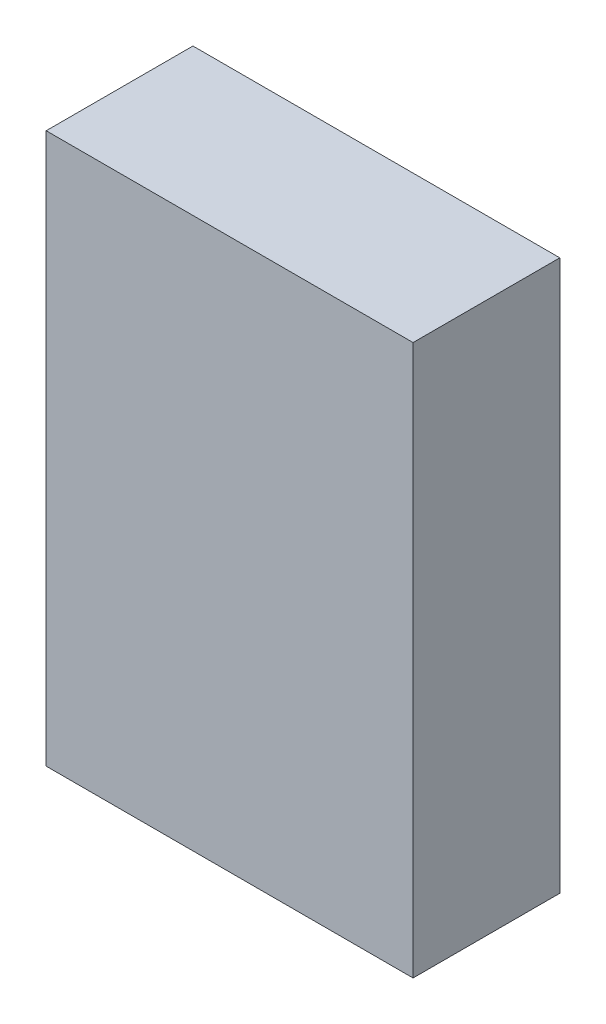
from build123d import *

# Parameters (mm, degrees)
ESQUISSE1_W             = 200
ESQUISSE1_H             = 300
BOSS_EXTRU_1_DEPTH      = 80
COQUE1_T                = -6
ESQUISSE3_W             = 194.2
ESQUISSE3_H             = 294.2
ENL_V_MAT_EXTRU_2_DEPTH = 6.1
ESQUISSE4_R             = 9
BOSS_EXTRU_2_DEPTH      = 67.9
ESQUISSE5_R             = 2.5
ENL_V_MAT_EXTRU_3_DEPTH = 30
ESQUISSE4_4_R           = 9
BOSS_EXTRU_3_DEPTH      = 15
ESQUISSE6_R             = 2.5
ENL_V_MAT_EXTRU_6_DEPTH = 10
ESQUISSE8_R             = 9
BOSS_EXTRU_5_DEPTH      = 68
ESQUISSE9_R             = 2.5
ENL_V_MAT_EXTRU_8_DEPTH = 30


with BuildPart() as part:
    # Esquisse1 → Boss.-Extru.1 (new body)
    with BuildSketch(Plane.XY):
        with Locations((43.373964051, -118.711656442)):
            Rectangle(ESQUISSE1_W, ESQUISSE1_H)
    extrude(amount=BOSS_EXTRU_1_DEPTH)

    # Coque1
    coque1_openings = [part.faces().sort_by_distance(p)[0] for p in [
        (43.373964051, -118.711656442, 0),
    ]]
    offset(amount=COQUE1_T, openings=coque1_openings, kind=Kind.INTERSECTION)

    # Esquisse3 → Enlèv. mat.-Extru.2 (cut)
    with BuildSketch(Plane(origin=(0, 0, 0), x_dir=(-1, 0, 0), z_dir=(0, 0, -1))):
        with Locations((-43.373964051, -118.711656442)):
            Rectangle(ESQUISSE3_W, ESQUISSE3_H)
    extrude(amount=-ENL_V_MAT_EXTRU_2_DEPTH, mode=Mode.SUBTRACT)

    # Esquisse4 → Boss.-Extru.2 (add)
    with BuildSketch(Plane(origin=(0, 0, 74), x_dir=(-1, 0, 0), z_dir=(0, 0, -1))):
        with Locations((-117.373964051, 5.288343558)):
            Circle(ESQUISSE4_R)
    extrude(amount=BOSS_EXTRU_2_DEPTH)

    # Esquisse5 → Enlèv. mat.-Extru.3 (cut)
    with BuildSketch(Plane(origin=(0, 0, 6.1), x_dir=(-1, 0, 0), z_dir=(0, 0, -1))):
        with Locations((-117.373964051, 5.288343558)):
            Circle(ESQUISSE5_R)
    extrude(amount=-ENL_V_MAT_EXTRU_3_DEPTH, mode=Mode.SUBTRACT)

    # Esquisse4_4 → Boss.-Extru.3 (add)
    with BuildSketch(Plane(origin=(0, 0, 74), x_dir=(-1, 0, 0), z_dir=(0, 0, -1))):
        with Locations((13.126035949, -183.711656442)):
            Circle(ESQUISSE4_4_R)
        with Locations((-99.873964051, -183.711656442)):
            Circle(ESQUISSE4_4_R)
        with Locations((-99.873964051, -53.711656442)):
            Circle(ESQUISSE4_4_R)
        with Locations((13.126035949, -53.711656442)):
            Circle(ESQUISSE4_4_R)
    extrude(amount=BOSS_EXTRU_3_DEPTH)

    # Esquisse6 → Enlèv. mat.-Extru.6 (cut)
    with BuildSketch(Plane(origin=(0, 0, 59), x_dir=(-1, 0, 0), z_dir=(0, 0, -1))):
        with Locations((-99.873964051, -53.711656442)):
            Circle(ESQUISSE6_R)
        with Locations((13.126035949, -53.711656442)):
            Circle(ESQUISSE6_R)
        with Locations((-99.873964051, -183.711656442)):
            Circle(ESQUISSE6_R)
        with Locations((13.126035949, -183.711656442)):
            Circle(ESQUISSE6_R)
    extrude(amount=-ENL_V_MAT_EXTRU_6_DEPTH, mode=Mode.SUBTRACT)

    # Esquisse8 → Boss.-Extru.5 (add)
    with BuildSketch(Plane(origin=(0, 0, 74), x_dir=(-1, 0, 0), z_dir=(0, 0, -1))):
        with Locations((30.626035949, 5.288343558)):
            Circle(ESQUISSE8_R)
        with Locations((30.626035949, -242.711656442)):
            Circle(ESQUISSE8_R)
        with Locations((-117.373964051, -242.711656442)):
            Circle(ESQUISSE8_R)
    extrude(amount=BOSS_EXTRU_5_DEPTH)

    # Esquisse9 → Enlèv. mat.-Extru.8 (cut)
    with BuildSketch(Plane(origin=(0, 0, 6), x_dir=(-1, 0, 0), z_dir=(0, 0, -1))):
        with Locations((30.626035949, 5.288343558)):
            Circle(ESQUISSE9_R)
        with Locations((30.626035949, -242.711656442)):
            Circle(ESQUISSE9_R)
        with Locations((-117.373964051, -242.711656442)):
            Circle(ESQUISSE9_R)
    extrude(amount=-ENL_V_MAT_EXTRU_8_DEPTH, mode=Mode.SUBTRACT)


with BuildPart() as part_1:
    # Corps-Déplacer/Copier1: moved
    add(part.part.moved(Location((0, 114, 0))))


with BuildPart() as part_2:
    # Corps-Déplacer/Copier2: moved
    add(part_1.part.moved(Location((0, 20, 0))))


solid = part_2.part
